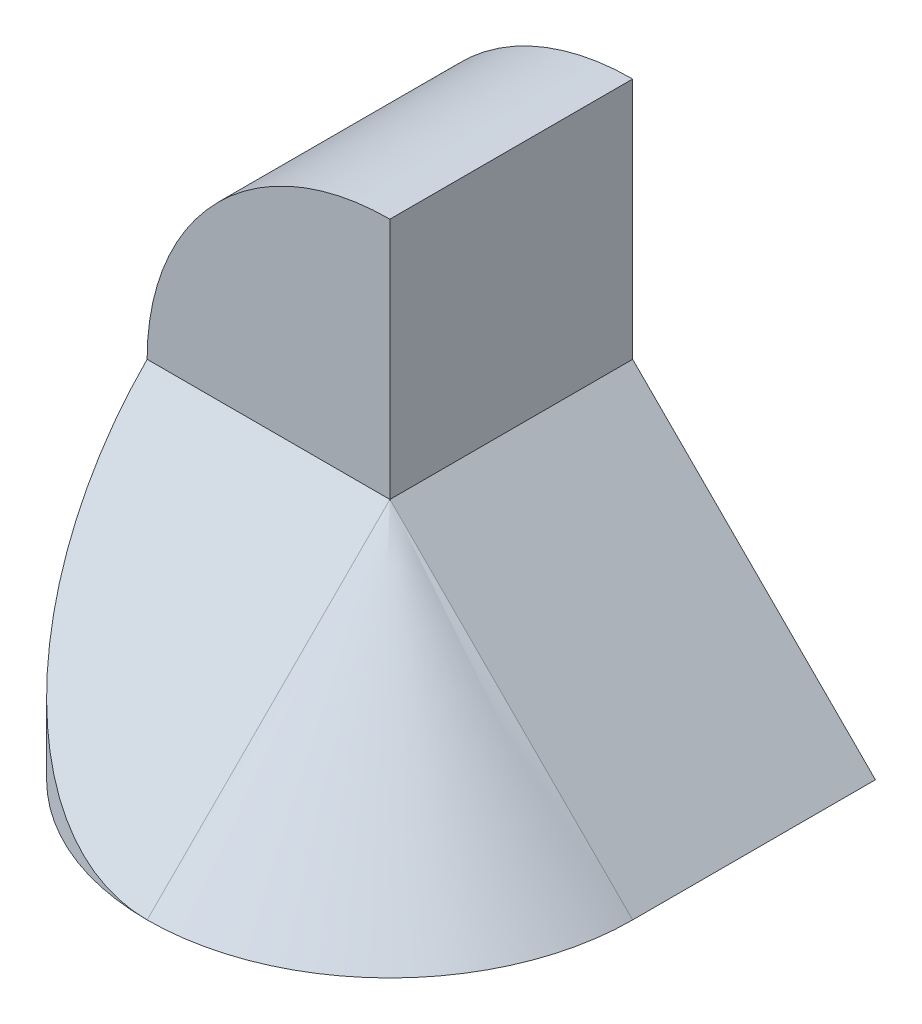
from build123d import *

# Parameters (mm, degrees)
BOSS_EXTRUDE1_DEPTH = 2
REVOLVE1_ANGLE      = 90
BOSS_EXTRUDE2_DEPTH = 2
CUT_EXTRUDE1_DEPTH  = 2
CUT_EXTRUDE2_DEPTH  = 1
BOSS_EXTRUDE3_DEPTH = 2


with BuildPart() as part:
    # Sketch1 → Boss-Extrude1 (new body)
    with BuildSketch(Plane.XY):
        with BuildLine():
            Line((0, 0), (2, 0))
            Line((2, 0), (2, 4))
            ThreePointArc((2, 4), (0.585786438, 3.414213562), (0, 2))
            Line((0, 2), (0, 0))
        make_face()
    extrude(amount=BOSS_EXTRUDE1_DEPTH)

    # Sketch4 → Boss-Extrude2 (add)
    with BuildSketch(Plane.ZY.offset(-2)):
        Polygon((2, 2), (2, 0), (4, 0), align=None)
    extrude(amount=BOSS_EXTRUDE2_DEPTH)

    # Sketch5 → Cut-Extrude1 (cut)
    with BuildSketch(Plane.XZ):
        with BuildLine():
            Line((2, 4), (0, 4))
            Line((0, 4), (0, 2))
            ThreePointArc((0, 2), (0.585786438, 3.414213562), (2, 4))
        make_face()
    extrude(amount=-CUT_EXTRUDE1_DEPTH, mode=Mode.SUBTRACT)

    # Sketch7 → Cut-Extrude2 (cut)
    with BuildSketch(Plane(origin=(0, 0, 0), x_dir=(-1, 0, 0), z_dir=(0, 0, -1))):
        with BuildLine():
            Line((-2, 0), (0, 0))
            Line((0, 0), (0, 2))
            ThreePointArc((0, 2), (-0.585786438, 0.585786438), (-2, 0))
        make_face()
    extrude(amount=-CUT_EXTRUDE2_DEPTH, mode=Mode.SUBTRACT)



with BuildPart() as body_2:
    # Sketch3 → Revolve1 (revolve)
    with BuildSketch(Plane.XY.offset(2)):
        Polygon((2, 2), (4, 0), (2, 0), align=None)
    revolve(axis=Axis((2, 2, 2), (0, -1, 0)), revolution_arc=REVOLVE1_ANGLE)


with BuildPart() as part_1:
    add(part.part)

    add(body_2.part)  # Boss-Extrude3 merges body 2
    # Sketch8 → Boss-Extrude3 (add)
    with BuildSketch(Plane(origin=(0, 0, 2), x_dir=(-1, 0, 0), z_dir=(0, 0, -1))):
        Polygon((-2, 2), (-2, 0), (-4, 0), align=None)
    extrude(amount=BOSS_EXTRUDE3_DEPTH)


solid = part_1.part
